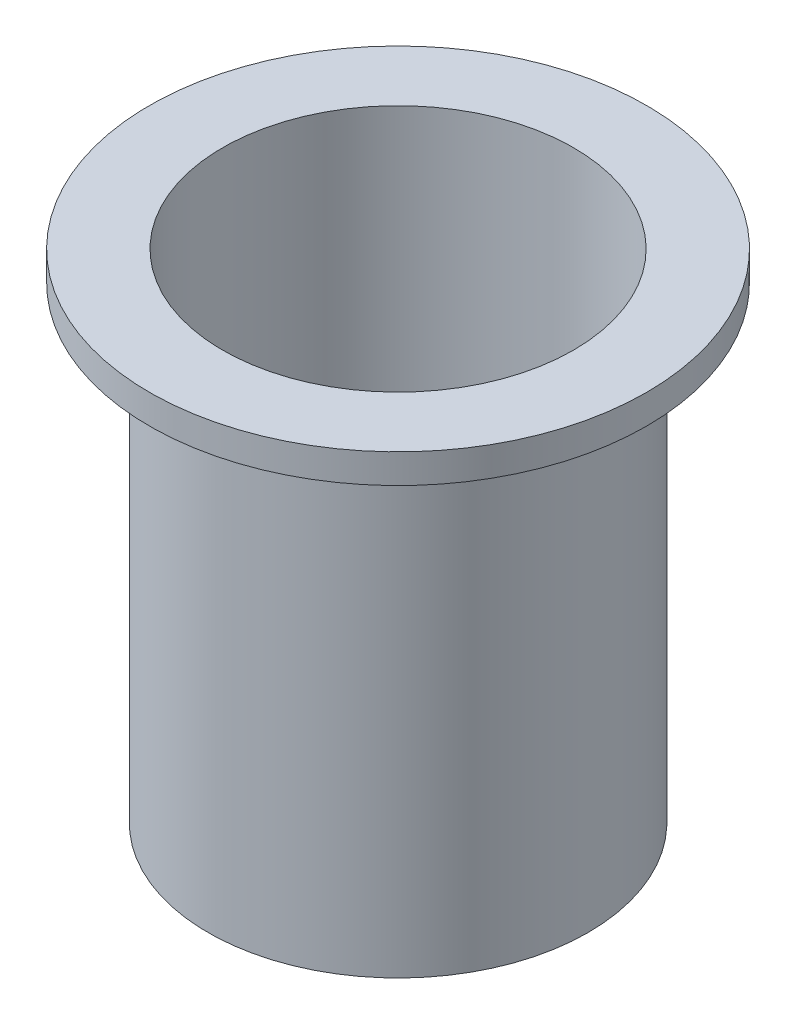
from build123d import *


with BuildPart() as part:
    # Sketch1 → Revolve1 (revolve)
    with BuildSketch(Plane.XY):
        Polygon((41.275, 0), (30.744042103, 0), (0, 0), (0, 3.175), (38.1, 3.175), (38.1, 107.95), (41.275, 107.95), (53.975, 107.95), (53.975, 101.6), (41.275, 101.6), align=None)
    revolve(axis=Axis((0, -554.392583441, 0), (0, 1, 0)))


solid = part.part
